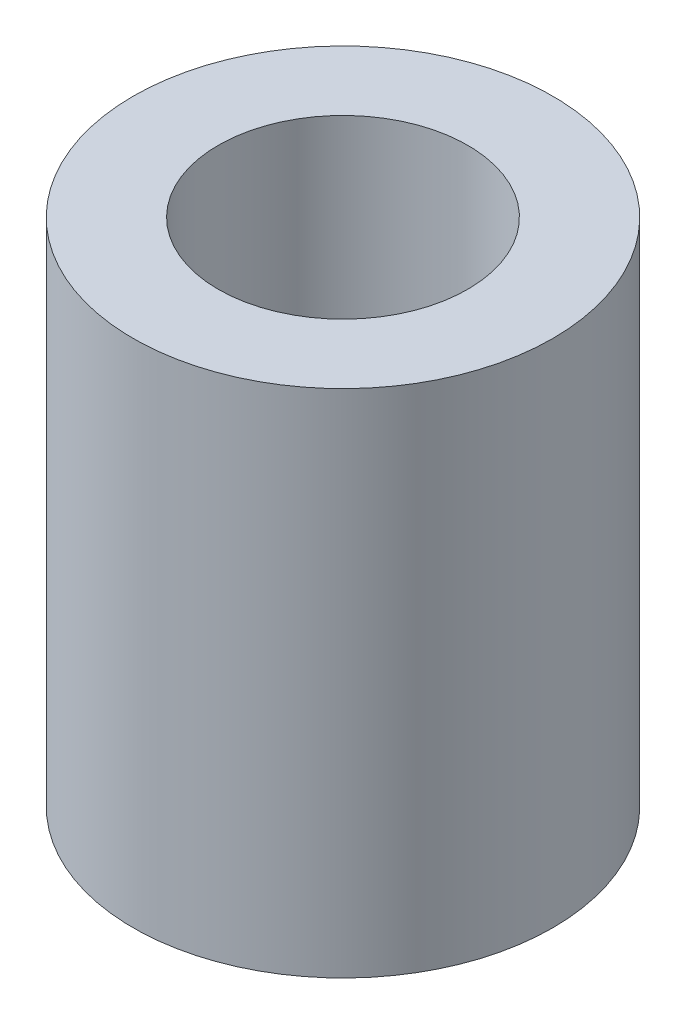
from build123d import *

# Parameters (mm, degrees)
SKETCH1_R           = 7.4
SKETCH1_R_2         = 4.4
EXTRUDE_THIN1_DEPTH = 18


with BuildPart() as part:
    # Sketch1 → Extrude-Thin1 (new body)
    with BuildSketch(Plane(origin=(0, 0, 0), x_dir=(1, 0, 0), z_dir=(0, 1, 0))):
        Circle(SKETCH1_R)
        Circle(SKETCH1_R_2, mode=Mode.SUBTRACT)
    extrude(amount=EXTRUDE_THIN1_DEPTH)


solid = part.part
